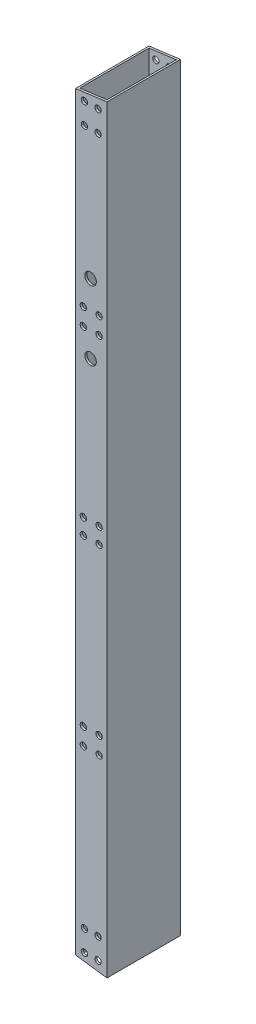
from build123d import *

# Parameters (mm, degrees)
SKETCH_1_W          = 30
SKETCH_1_H          = 750
SKETCH_1_R          = 2
EXTRUDE_2_DEPTH     = 70
SKETCH_2_W          = 26
SKETCH_2_H          = 66
CUT_EXTRUDE_3_DEPTH = 754.408919512
CUT_EXTRUDE_4_DEPTH = 382.772183376
SKETCH_8_R          = 3
SKETCH_8_R_2        = 2
CUT_EXTRUDE_6_DEPTH = 382.772183376
SKETCH_9_R          = 5.5
CUT_EXTRUDE_7_DEPTH = 316


with BuildPart() as part:
    # 草图1 → 凸台-拉伸2 (new body)
    with BuildSketch(Plane.XY):
        Rectangle(SKETCH_1_W, SKETCH_1_H)
        with Locations((-7.5, 194.978117754)):
            Circle(SKETCH_1_R, mode=Mode.SUBTRACT)
        with Locations((7.5, 194.978117754)):
            Circle(SKETCH_1_R, mode=Mode.SUBTRACT)
        with Locations((-7.5, 178.773554479)):
            Circle(SKETCH_1_R, mode=Mode.SUBTRACT)
        with Locations((7.5, 178.773554479)):
            Circle(SKETCH_1_R, mode=Mode.SUBTRACT)
        with Locations((-7.5, -150.877478615)):
            Circle(SKETCH_1_R, mode=Mode.SUBTRACT)
        with Locations((7.5, -150.877478615)):
            Circle(SKETCH_1_R, mode=Mode.SUBTRACT)
        with Locations((-7.5, -167.08204189)):
            Circle(SKETCH_1_R, mode=Mode.SUBTRACT)
        with Locations((7.5, -167.08204189)):
            Circle(SKETCH_1_R, mode=Mode.SUBTRACT)
    extrude(amount=EXTRUDE_2_DEPTH)

    # 草图2 → 切除-拉伸3 (cut, through all)
    with BuildSketch(Plane.XZ.offset(375)):
        with Locations((0, 35)):
            Rectangle(SKETCH_2_W, SKETCH_2_H)
    extrude(amount=-CUT_EXTRUDE_3_DEPTH, mode=Mode.SUBTRACT)

    # 草图3 → 切除-拉伸4 (cut, through all)
    with BuildSketch(Plane.XY.offset(70)):
        Polygon((15, -375), (15, -347.1), (-15, -343.150425072), (-15, -375), align=None)
        Polygon((15, 377.040830045), (15, 375), (-15, 371.050425072), (-15, 377.040830045), align=None)
    extrude(amount=-CUT_EXTRUDE_4_DEPTH, mode=Mode.SUBTRACT)

    # 草图8 → 切除-拉伸6 (cut, through all)
    with BuildSketch(Plane(origin=(0, 0, 0), x_dir=(-1, 0, 0), z_dir=(0, 0, -1))):
        with Locations((6.5, 364.870363851)):
            Circle(SKETCH_8_R)
        with Locations((-6.5, 364.870363851)):
            Circle(SKETCH_8_R)
        with Locations((-6.5, 344.870363851)):
            Circle(SKETCH_8_R)
        with Locations((6.5, 344.870363851)):
            Circle(SKETCH_8_R)
        with Locations((-7.5, -150.877478615)):
            Circle(SKETCH_8_R)
        with Locations((-7.5, -150.877478615)):
            Circle(SKETCH_8_R_2, mode=Mode.SUBTRACT)
        with Locations((7.5, -150.877478615)):
            Circle(SKETCH_8_R)
        with Locations((7.5, -150.877478615)):
            Circle(SKETCH_8_R_2, mode=Mode.SUBTRACT)
        with Locations((7.5, -167.08204189)):
            Circle(SKETCH_8_R)
        with Locations((7.5, -167.08204189)):
            Circle(SKETCH_8_R_2, mode=Mode.SUBTRACT)
        with Locations((-7.5, -167.08204189)):
            Circle(SKETCH_8_R)
        with Locations((-7.5, -167.08204189)):
            Circle(SKETCH_8_R_2, mode=Mode.SUBTRACT)
        with Locations((-7.49999999, 21.448037931)):
            Circle(SKETCH_8_R)
        with Locations((7.50000001, 21.448037931)):
            Circle(SKETCH_8_R)
        with Locations((-7.49999999, 6.448037931)):
            Circle(SKETCH_8_R)
        with Locations((7.50000001, 6.448037931)):
            Circle(SKETCH_8_R)
        with Locations((-7.5, 194.978117754)):
            Circle(SKETCH_8_R)
        with Locations((-7.5, 194.978117754)):
            Circle(SKETCH_8_R_2, mode=Mode.SUBTRACT)
        with Locations((-7.5, 178.773554479)):
            Circle(SKETCH_8_R)
        with Locations((-7.5, 178.773554479)):
            Circle(SKETCH_8_R_2, mode=Mode.SUBTRACT)
        with Locations((7.5, 194.978117754)):
            Circle(SKETCH_8_R)
        with Locations((7.5, 194.978117754)):
            Circle(SKETCH_8_R_2, mode=Mode.SUBTRACT)
        with Locations((7.5, 178.773554479)):
            Circle(SKETCH_8_R)
        with Locations((7.5, 178.773554479)):
            Circle(SKETCH_8_R_2, mode=Mode.SUBTRACT)
        with Locations((6.5, -316.970363851)):
            Circle(SKETCH_8_R)
        with Locations((-6.5, -316.970363851)):
            Circle(SKETCH_8_R)
        with Locations((-6.5, -336.970363851)):
            Circle(SKETCH_8_R)
        with Locations((6.5, -336.970363851)):
            Circle(SKETCH_8_R)
    extrude(amount=-CUT_EXTRUDE_6_DEPTH, mode=Mode.SUBTRACT)

    # 草图9 → 切除-拉伸7 (cut)
    with BuildSketch(Plane.XY.offset(70)):
        with Locations((-0.612697266, 155.502325872)):
            Circle(SKETCH_9_R)
        with Locations((-0.612697266, 221.502325872)):
            Circle(SKETCH_9_R)
    extrude(amount=-CUT_EXTRUDE_7_DEPTH, mode=Mode.SUBTRACT)


solid = part.part
